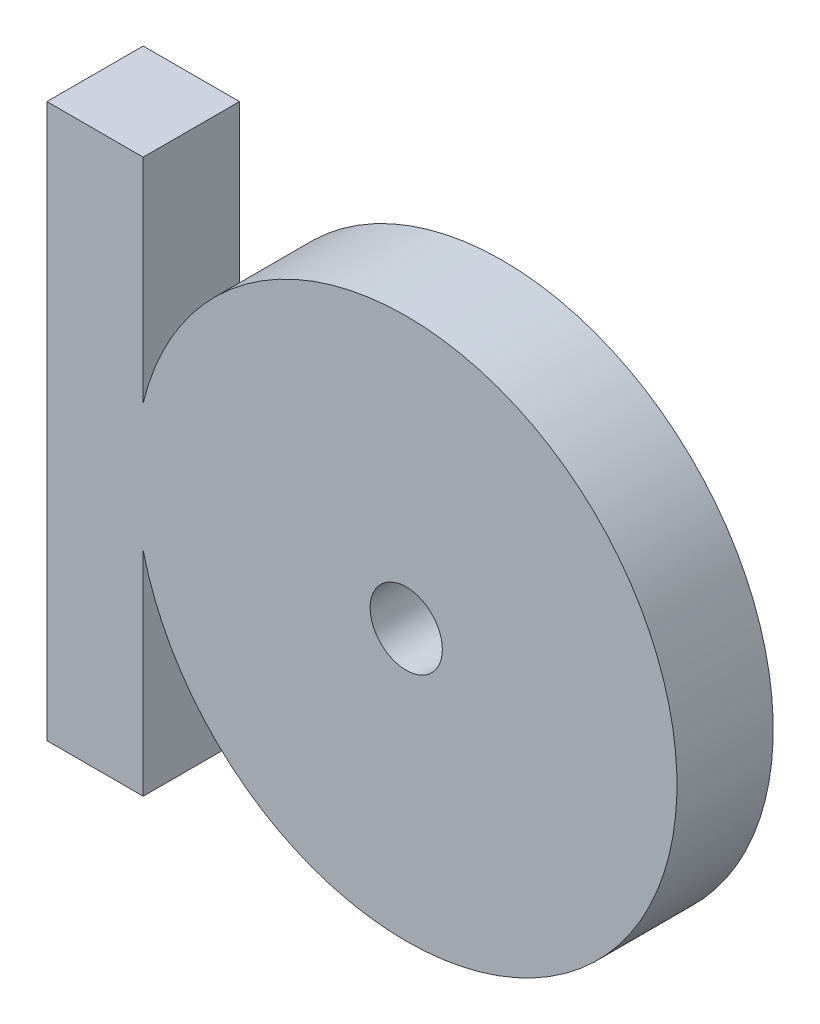
from build123d import *

# Parameters (mm, degrees)
SKETCH_1_R      = 1.5
EXTRUDE_1_DEPTH = 4


with BuildPart() as part:
    # Эскиз1 → Бобышка-Вытянуть1 (new body)
    with BuildSketch(Plane.XY):
        with BuildLine():
            Line((4, 0), (4, 8.841521673))
            ThreePointArc((4, 8.841521673), (26.181376537, 11.5), (4, 14.158478327))
            Line((4, 14.158478327), (4, 23))
            Line((4, 23), (0, 23))
            Line((0, 23), (0, 0))
            Line((0, 0), (4, 0))
        make_face()
        with Locations((14.931376537, 11.5)):
            Circle(SKETCH_1_R, mode=Mode.SUBTRACT)
    extrude(amount=EXTRUDE_1_DEPTH)


solid = part.part
